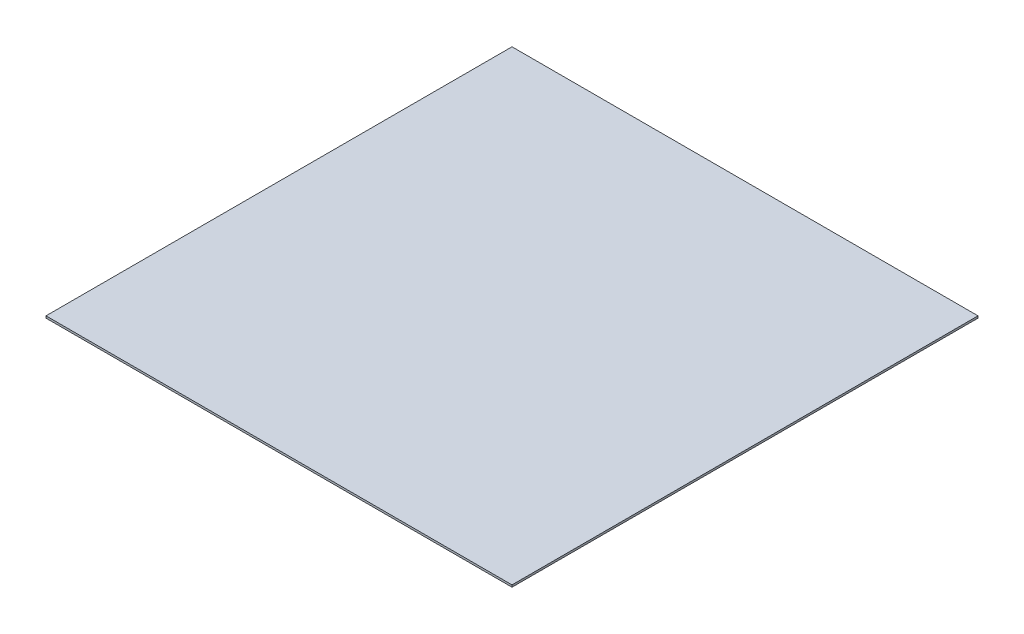
from build123d import *

# Parameters (mm, degrees)
SKETCH1_W           = 298
SKETCH1_H           = 298
BOSS_EXTRUDE1_DEPTH = 1.3


with BuildPart() as part:
    # Sketch1 → Boss-Extrude1 (new body)
    with BuildSketch(Plane(origin=(0, 0, 0), x_dir=(1, 0, 0), z_dir=(0, 1, 0))):
        Rectangle(SKETCH1_W, SKETCH1_H)
    extrude(amount=BOSS_EXTRUDE1_DEPTH)


solid = part.part
